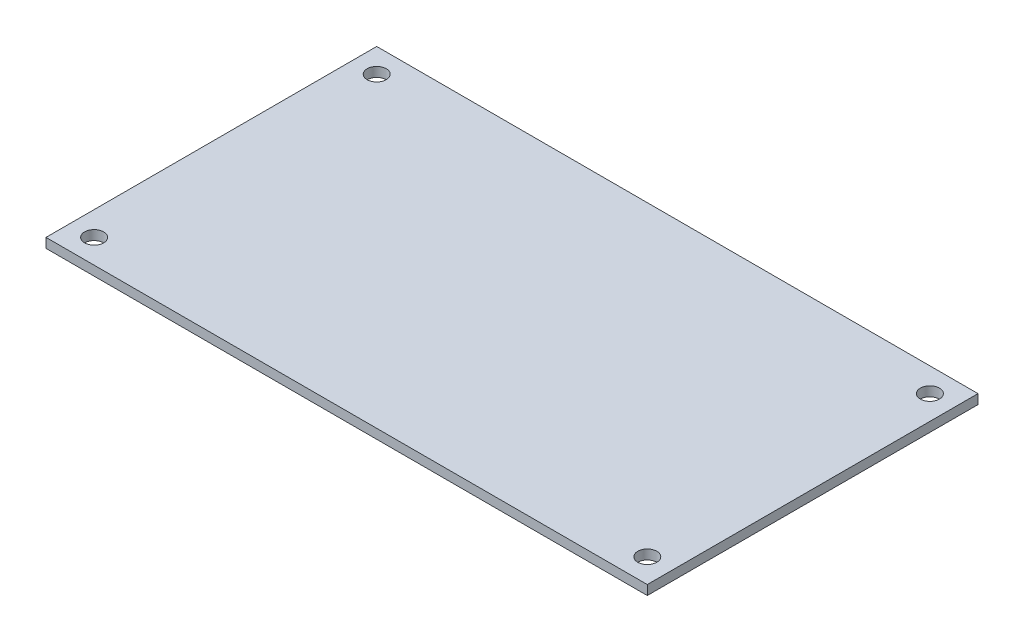
from build123d import *

# Parameters (mm, degrees)
SKETCH1_W           = 200
SKETCH1_H           = 110
BOSS_EXTRUDE1_DEPTH = 3.175
CUT_EXTRUDE1_REACH  = 5.175
SKETCH2_R           = 3.175


with BuildPart() as part:
    # Sketch1 → Boss-Extrude1 (new body)
    with BuildSketch(Plane(origin=(0, 0, 0), x_dir=(1, 0, 0), z_dir=(0, 1, 0))):
        with Locations((100, 55)):
            Rectangle(SKETCH1_W, SKETCH1_H)
    extrude(amount=BOSS_EXTRUDE1_DEPTH)

    # Sketch2 → Cut-Extrude1 (cut, up to next)
    with BuildSketch(Plane(origin=(0, 3.175, 0), x_dir=(1, 0, 0), z_dir=(0, 1, 0)), mode=Mode.PRIVATE) as cut_extrude1_sk1:
        with Locations((8, 102)):
            Circle(SKETCH2_R)
    cut_extrude1_tool1 = extrude(cut_extrude1_sk1.sketch, amount=-CUT_EXTRUDE1_REACH, mode=Mode.PRIVATE) & part.part
    add(cut_extrude1_tool1.solids().sort_by_distance((8, 3.175, -102))[0], mode=Mode.SUBTRACT)
    # Sketch2 → Cut-Extrude1 (cut, up to next)
    with BuildSketch(Plane(origin=(0, 3.175, 0), x_dir=(1, 0, 0), z_dir=(0, 1, 0)), mode=Mode.PRIVATE) as cut_extrude1_sk2:
        with Locations((192, 102)):
            Circle(SKETCH2_R)
    cut_extrude1_tool2 = extrude(cut_extrude1_sk2.sketch, amount=-CUT_EXTRUDE1_REACH, mode=Mode.PRIVATE) & part.part
    add(cut_extrude1_tool2.solids().sort_by_distance((192, 3.175, -102))[0], mode=Mode.SUBTRACT)
    # Sketch2 → Cut-Extrude1 (cut, up to next)
    with BuildSketch(Plane(origin=(0, 3.175, 0), x_dir=(1, 0, 0), z_dir=(0, 1, 0)), mode=Mode.PRIVATE) as cut_extrude1_sk3:
        with Locations((192, 8)):
            Circle(SKETCH2_R)
    cut_extrude1_tool3 = extrude(cut_extrude1_sk3.sketch, amount=-CUT_EXTRUDE1_REACH, mode=Mode.PRIVATE) & part.part
    add(cut_extrude1_tool3.solids().sort_by_distance((192, 3.175, -8))[0], mode=Mode.SUBTRACT)
    # Sketch2 → Cut-Extrude1 (cut, up to next)
    with BuildSketch(Plane(origin=(0, 3.175, 0), x_dir=(1, 0, 0), z_dir=(0, 1, 0)), mode=Mode.PRIVATE) as cut_extrude1_sk4:
        with Locations((8, 8)):
            Circle(SKETCH2_R)
    cut_extrude1_tool4 = extrude(cut_extrude1_sk4.sketch, amount=-CUT_EXTRUDE1_REACH, mode=Mode.PRIVATE) & part.part
    add(cut_extrude1_tool4.solids().sort_by_distance((8, 3.175, -8))[0], mode=Mode.SUBTRACT)


solid = part.part
